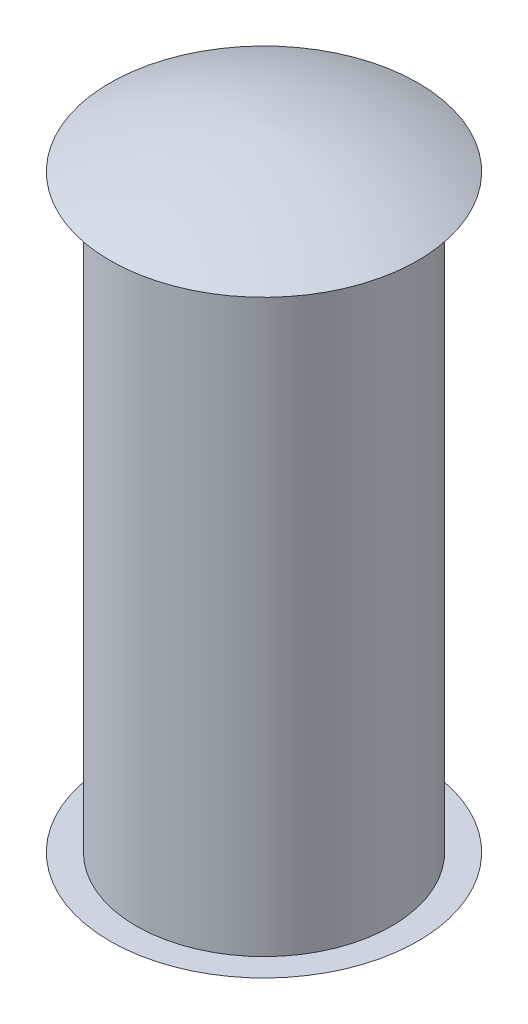
from build123d import *

# Parameters (mm, degrees)
SKETCH1_R           = 9.75
BOSS_EXTRUDE1_DEPTH = 22.5


with BuildPart() as part:
    # Sketch1 → Boss-Extrude1 (new body)
    with BuildSketch(Plane(origin=(0, 0, 0), x_dir=(1, 0, 0), z_dir=(0, 1, 0))):
        Circle(SKETCH1_R)
    boss_extrude1 = extrude(amount=BOSS_EXTRUDE1_DEPTH)

    # Sketch2 → Revolve1 (revolve)
    with BuildSketch(Plane.XY):
        with BuildLine():
            Line((0, 22.5), (0, 25.5))
            ThreePointArc((0, 25.5), (6.028167217, 24.599904934), (11.75, 22.5))
            Line((11.75, 22.5), (0, 22.5))
        make_face()
    revolve1 = revolve(axis=Axis((0, 22.5, 0), (0, 1, 0)))

    # Mirror1: Boss-Extrude1, Revolve1 across plane
    add(boss_extrude1.mirror(Plane.ZX))
    add(revolve1.mirror(Plane.ZX))


solid = part.part
